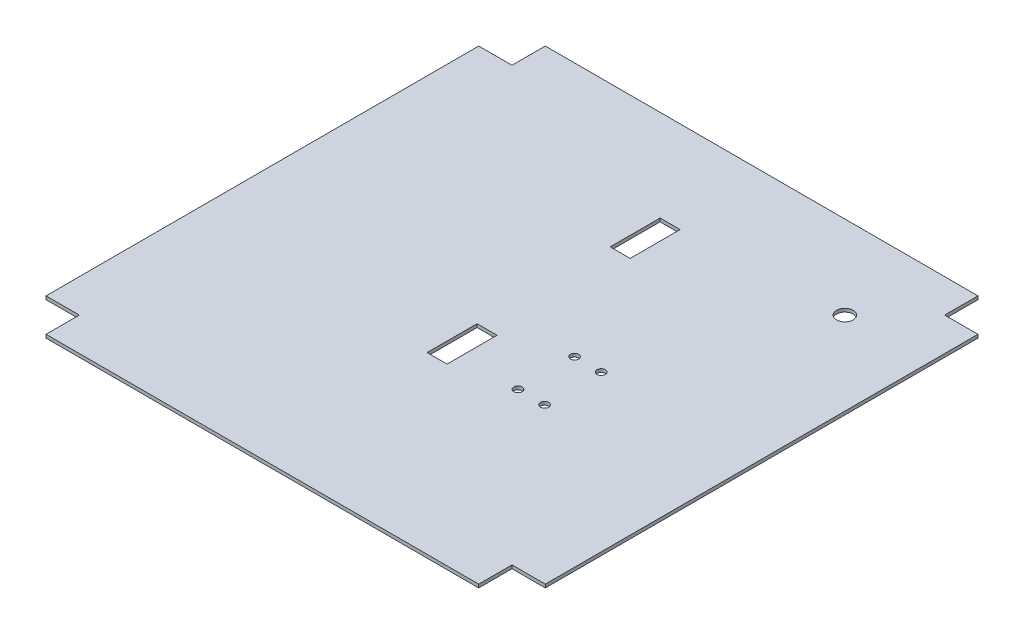
from build123d import *

# Parameters (mm, degrees)
BOSS_EXTRUDE1_DEPTH = 2
SKETCH2_R           = 5
SKETCH2_R_2         = 2.5
SKETCH2_W           = 12
SKETCH2_H           = 30
CUT_EXTRUDE1_DEPTH  = 10


with BuildPart() as part:
    # Sketch1 → Boss-Extrude1 (new body)
    with BuildSketch(Plane(origin=(0, 0, 0), x_dir=(1, 0, 0), z_dir=(0, 1, 0))):
        Polygon((-130, 150), (-130, 130), (-150, 130), (-150, -130), (-130, -130), (-130, -150), (130, -150), (130, -130), (150, -130), (150, 130), (130, 130), (130, 150), align=None)
    extrude(amount=BOSS_EXTRUDE1_DEPTH)

    # Sketch2 → Cut-Extrude1 (cut)
    with BuildSketch(Plane(origin=(0, 2, 0), x_dir=(1, 0, 0), z_dir=(0, 1, 0))):
        with Locations((100, 100)):
            Circle(SKETCH2_R)
        with Locations((56.45, -2.85)):
            Circle(SKETCH2_R_2)
        with Locations((40.45, -2.85)):
            Circle(SKETCH2_R_2)
        with Locations((40.45, -36.85)):
            Circle(SKETCH2_R_2)
        with Locations((56.45, -36.85)):
            Circle(SKETCH2_R_2)
        with Locations((0, -30)):
            Rectangle(SKETCH2_W, SKETCH2_H)
        with Locations((0, 80)):
            Rectangle(SKETCH2_W, SKETCH2_H)
    extrude(amount=-CUT_EXTRUDE1_DEPTH, mode=Mode.SUBTRACT)


solid = part.part
